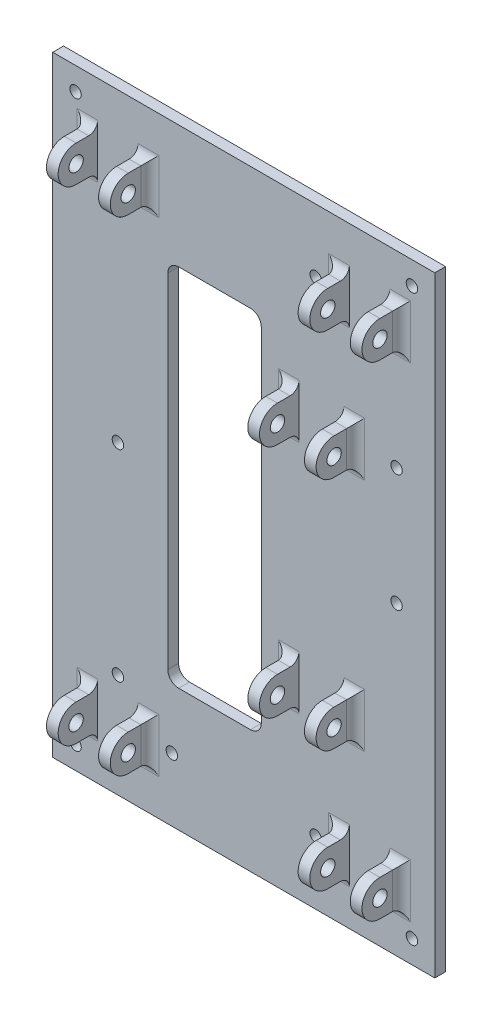
from build123d import *

# Parameters (mm, degrees)
SKETCH1_W               = 212.5
SKETCH1_H               = 339.725
BOSS_EXTRUDE1_DEPTH     = 6
SKETCH2_W               = 6.5
SKETCH2_H               = 20
BOSS_EXTRUDE2_DEPTH     = 24
CUT_EXTRUDE1_DEPTH      = 393.36344838
CUT_EXTRUDE1_DEPTH_BACK = 393.36344838
SKETCH3_R               = 4
FILLET2_R               = 5
SKETCH5_R               = 3.175
CUT_EXTRUDE2_DEPTH      = 402.314497153
CUT_EXTRUDE3_DEPTH      = 402.314497153


with BuildPart() as part:
    # Sketch1 → Boss-Extrude1 (new body)
    with BuildSketch(Plane.XY):
        with Locations((106.25, -169.8625)):
            Rectangle(SKETCH1_W, SKETCH1_H)
    extrude(amount=BOSS_EXTRUDE1_DEPTH)

    # Sketch2 → Boss-Extrude2 (add)
    with BuildSketch(Plane.XY.offset(6)):
        with Locations((21.75, -35.2425)):
            Rectangle(SKETCH2_W, SKETCH2_H)
        with Locations((50.75, -35.2425)):
            Rectangle(SKETCH2_W, SKETCH2_H)
        with Locations((161.75, -35.2425)):
            Rectangle(SKETCH2_W, SKETCH2_H)
        with Locations((190.75, -35.2425)):
            Rectangle(SKETCH2_W, SKETCH2_H)
        with Locations((133.75, -104.5325)):
            Rectangle(SKETCH2_W, SKETCH2_H)
        with Locations((165.25, -104.5325)):
            Rectangle(SKETCH2_W, SKETCH2_H)
        with Locations((165.25, -235.1925)):
            Rectangle(SKETCH2_W, SKETCH2_H)
        with Locations((21.75, -304.4825)):
            Rectangle(SKETCH2_W, SKETCH2_H)
        with Locations((50.75, -304.4825)):
            Rectangle(SKETCH2_W, SKETCH2_H)
        with Locations((190.75, -304.4825)):
            Rectangle(SKETCH2_W, SKETCH2_H)
        with Locations((161.75, -304.4825)):
            Rectangle(SKETCH2_W, SKETCH2_H)
        with Locations((133.75, -235.1925)):
            Rectangle(SKETCH2_W, SKETCH2_H)
    extrude(amount=BOSS_EXTRUDE2_DEPTH)

    # Sketch3 → Cut-Extrude1 (cut, two sides: drawn at the far end of the back side and taken through both)
    with BuildSketch(Plane.ZY.offset(-18.5).offset(-CUT_EXTRUDE1_DEPTH_BACK)):
        with Locations((18, -35.2425)):
            Circle(SKETCH3_R)
        with Locations((18, -235.1925)):
            Circle(SKETCH3_R)
        with Locations((18, -304.4825)):
            Circle(SKETCH3_R)
        with Locations((18, -104.5325)):
            Circle(SKETCH3_R)
        with BuildLine():
            Line((18, -25.2425), (18, -12.982943413))
            Line((18, -12.982943413), (51.949532367, -12.982943413))
            Line((51.949532367, -12.982943413), (51.949532367, -57.481006387))
            Line((51.949532367, -57.481006387), (18, -57.481006387))
            Line((18, -57.481006387), (18, -45.2425))
            ThreePointArc((18, -45.2425), (28, -35.2425), (18, -25.2425))
        make_face()
        with BuildLine():
            Line((52.442304634, -132.399123951), (18, -132.399123951))
            Line((18, -132.399123951), (18, -114.5325))
            ThreePointArc((18, -114.5325), (28, -104.5325), (18, -94.5325))
            Line((18, -94.5325), (18, -71.59149594))
            Line((18, -71.59149594), (52.442304634, -71.59149594))
            Line((52.442304634, -71.59149594), (52.442304634, -132.399123951))
        make_face()
        with BuildLine():
            Line((52.599532243, -270.375386727), (18, -270.375386727))
            Line((18, -270.375386727), (18, -245.1925))
            ThreePointArc((18, -245.1925), (28, -235.1925), (18, -225.1925))
            Line((18, -225.1925), (18, -207.306351849))
            Line((18, -207.306351849), (52.599532243, -207.306351849))
            Line((52.599532243, -207.306351849), (52.599532243, -270.375386727))
        make_face()
        with BuildLine():
            Line((52.621034016, -326.721115515), (18, -326.721115515))
            Line((18, -326.721115515), (18, -314.4825))
            ThreePointArc((18, -314.4825), (28, -304.4825), (18, -294.4825))
            Line((18, -294.4825), (18, -282.222834285))
            Line((18, -282.222834285), (52.621034016, -282.222834285))
            Line((52.621034016, -282.222834285), (52.621034016, -326.721115515))
        make_face()
    extrude(amount=CUT_EXTRUDE1_DEPTH + CUT_EXTRUDE1_DEPTH_BACK, mode=Mode.SUBTRACT)

    # Fillet2
    fillet2_edges = [part.edges().sort_by_distance(p)[0] for p in [
        (158.5, -304.4825, 6),
        (18.5, -304.4825, 6),
        (21.75, -45.2425, 6),
        (18.5, -35.2425, 6),
        (21.75, -25.2425, 6),
        (50.75, -25.2425, 6),
        (50.75, -45.2425, 6),
        (54, -35.2425, 6),
        (161.75, -25.2425, 6),
        (190.75, -25.2425, 6),
        (194, -35.2425, 6),
        (190.75, -45.2425, 6),
        (161.75, -45.2425, 6),
        (158.5, -35.2425, 6),
        (168.5, -104.5325, 6),
        (165.25, -114.5325, 6),
        (133.75, -114.5325, 6),
        (130.5, -104.5325, 6),
        (165.25, -94.5325, 6),
        (133.75, -94.5325, 6),
        (21.75, -294.4825, 6),
        (50.75, -294.4825, 6),
        (54, -304.4825, 6),
        (194, -304.4825, 6),
        (161.75, -294.4825, 6),
        (190.75, -294.4825, 6),
        (190.75, -314.4825, 6),
        (161.75, -314.4825, 6),
        (50.75, -314.4825, 6),
        (21.75, -314.4825, 6),
        (165.25, -225.1925, 6),
        (133.75, -225.1925, 6),
        (130.5, -235.1925, 6),
        (133.75, -245.1925, 6),
        (165.25, -245.1925, 6),
        (168.5, -235.1925, 6),
    ]]
    fillet(fillet2_edges, radius=FILLET2_R)

    # Sketch5 → Cut-Extrude2 (cut, through all)
    with BuildSketch(Plane.XY.offset(6)):
        with Locations((12.7, -12.7)):
            Circle(SKETCH5_R)
        with Locations((199.8, -12.7)):
            Circle(SKETCH5_R)
        with Locations((146.25, -35.2425)):
            Circle(SKETCH5_R)
        with Locations((176.25, -57.8625)):
            Circle(SKETCH5_R)
        with Locations((36.25, -57.8625)):
            Circle(SKETCH5_R)
        with Locations((191.25, -104.5325)):
            Circle(SKETCH5_R)
        with Locations((36.25, -169.8625)):
            Circle(SKETCH5_R)
        with Locations((191.25, -169.8625)):
            Circle(SKETCH5_R)
        with Locations((36.25, -281.8625)):
            Circle(SKETCH5_R)
        with Locations((66.25, -304.4825)):
            Circle(SKETCH5_R)
        with Locations((12.7, -327.025)):
            Circle(SKETCH5_R)
        with Locations((199.8, -327.025)):
            Circle(SKETCH5_R)
        with Locations((146.25, -304.4825)):
            Circle(SKETCH5_R)
    extrude(amount=-CUT_EXTRUDE2_DEPTH, mode=Mode.SUBTRACT)

    # Sketch9 → Cut-Extrude3 (cut, through all)
    with BuildSketch(Plane.XY.offset(6)):
        with BuildLine():
            ThreePointArc((64, -265.3625), (65.757359313, -269.605140687), (70, -271.3625))
            Line((70, -271.3625), (110, -271.3625))
            ThreePointArc((110, -271.3625), (114.242640687, -269.605140687), (116, -265.3625))
            Line((116, -265.3625), (116, -74.3625))
            ThreePointArc((116, -74.3625), (114.242640687, -70.119859313), (110, -68.3625))
            Line((110, -68.3625), (70, -68.3625))
            ThreePointArc((70, -68.3625), (65.757359313, -70.119859313), (64, -74.3625))
            Line((64, -74.3625), (64, -265.3625))
        make_face()
    extrude(amount=-CUT_EXTRUDE3_DEPTH, mode=Mode.SUBTRACT)


solid = part.part
